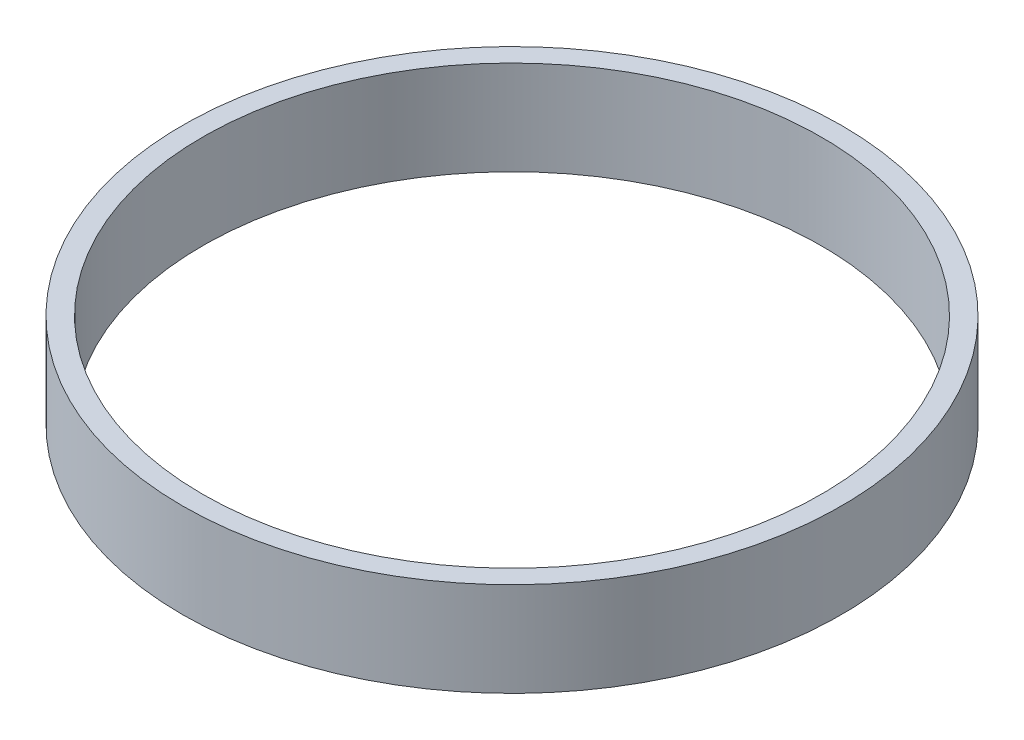
from build123d import *

# Parameters (mm, degrees)
SKETCH1_R           = 24.5
SKETCH1_R_2         = 23
BOSS_EXTRUDE1_DEPTH = 7


with BuildPart() as part:
    # Sketch1 → Boss-Extrude1 (new body)
    with BuildSketch(Plane(origin=(0, 0, 0), x_dir=(1, 0, 0), z_dir=(0, 1, 0))):
        Circle(SKETCH1_R)
        Circle(SKETCH1_R_2, mode=Mode.SUBTRACT)
    extrude(amount=BOSS_EXTRUDE1_DEPTH)


solid = part.part
